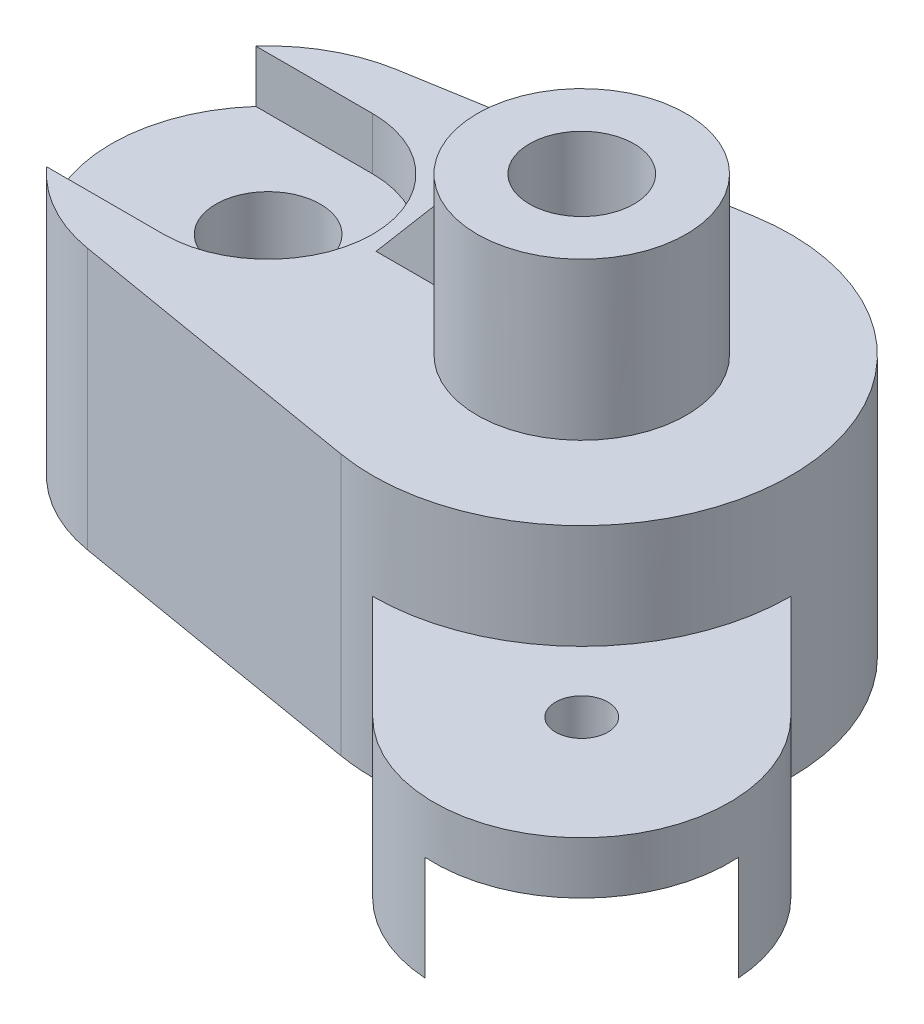
from build123d import *

# Parameters (mm, degrees)
BOSS_EXTRUDE1_DEPTH        = 50
SKETCH2_R                  = 30
CUT_EXTRUDE1_DEPTH         = 30
SKETCH3_R                  = 20
BOSS_EXTRUDE2_DEPTH        = 30
F_20_0MM_DOWEL_HOLE1_D     = 20
F_20_0MM_DOWEL_HOLE1_DEPTH = 30
F_20_0MM_DOWEL_HOLE1_TIP   = 6.00860619
SKETCH6_R                  = 10
CUT_EXTRUDE2_DEPTH         = 109
SKETCH7_R                  = 10
CUT_EXTRUDE3_DEPTH         = 10
BOSS_EXTRUDE3_DEPTH        = 30
SKETCH11_R                 = 5
CUT_EXTRUDE4_DEPTH         = 30
SKETCH13_R                 = 5
CUT_EXTRUDE5_DEPTH         = 20
SKETCH14_W                 = 17
SKETCH14_H                 = 5
BOSS_EXTRUDE4_DEPTH        = 20
SKETCH15_W                 = 91.222515674
SKETCH15_H                 = 40
CUT_EXTRUDE6_DEPTH         = 20
CUT_EXTRUDE7_DEPTH         = 20


with BuildPart() as part:
    # Sketch1 → Boss-Extrude1 (new body)
    with BuildSketch(Plane(origin=(0, 0, 0), x_dir=(1, 0, 0), z_dir=(0, 1, 0))):
        with BuildLine():
            Line((-6.666666667, 39.440531887), (-65, 29.580398915))
            ThreePointArc((-65, 29.580398915), (-74.494747679, 26.265991124), (-82.360679775, 20))
            ThreePointArc((-82.360679775, 20), (-90, 0), (-82.360679775, -20))
            ThreePointArc((-82.360679775, -20), (-74.494747679, -26.265991124), (-65, -29.580398915))
            Line((-65, -29.580398915), (-6.666666667, -39.440531887))
            ThreePointArc((-6.666666667, -39.440531887), (-3.345050411, -39.859887578), (0, -40))
            ThreePointArc((0, -40), (40, 0), (0, 40))
            ThreePointArc((0, 40), (-3.345050411, 39.859887578), (-6.666666667, 39.440531887))
        make_face()
    extrude(amount=BOSS_EXTRUDE1_DEPTH)

    # Sketch2 → Cut-Extrude1 (cut)
    with BuildSketch(Plane.XZ):
        Circle(SKETCH2_R)
    extrude(amount=-CUT_EXTRUDE1_DEPTH, mode=Mode.SUBTRACT)

    # Sketch3 → Boss-Extrude2 (add)
    with BuildSketch(Plane(origin=(0, 50, 0), x_dir=(1, 0, 0), z_dir=(0, 1, 0))):
        Circle(SKETCH3_R)
    extrude(amount=BOSS_EXTRUDE2_DEPTH)

    # Ø20.0mm Dowel Hole1
    with Locations(Plane.ZX.offset(80)):
        with Locations((0, 0)):
            Hole(F_20_0MM_DOWEL_HOLE1_D / 2, depth=F_20_0MM_DOWEL_HOLE1_DEPTH)
            with Locations((0, 0, -(F_20_0MM_DOWEL_HOLE1_DEPTH + F_20_0MM_DOWEL_HOLE1_TIP / 2))):  # 118° drill point
                Cone(0, F_20_0MM_DOWEL_HOLE1_D / 2, F_20_0MM_DOWEL_HOLE1_TIP, mode=Mode.SUBTRACT)

    # Sketch6 → Cut-Extrude2 (cut)
    with BuildSketch(Plane(origin=(0, 50, 0), x_dir=(1, 0, 0), z_dir=(0, 1, 0))):
        with Locations((-60, 0)):
            Circle(SKETCH6_R)
    extrude(amount=-CUT_EXTRUDE2_DEPTH, mode=Mode.SUBTRACT)

    # Sketch7 → Cut-Extrude3 (cut)
    with BuildSketch(Plane(origin=(0, 50, 0), x_dir=(1, 0, 0), z_dir=(0, 1, 0))):
        with BuildLine():
            ThreePointArc((-60, -20), (-40, 0), (-60, 20))
            Line((-60, 20), (-82.360679775, 20))
            ThreePointArc((-82.360679775, 20), (-90, 0), (-82.360679775, -20))
            Line((-82.360679775, -20), (-60, -20))
        make_face()
        with Locations((-60, 0)):
            Circle(SKETCH7_R, mode=Mode.SUBTRACT)
    extrude(amount=-CUT_EXTRUDE3_DEPTH, mode=Mode.SUBTRACT)

    # Sketch10 → Boss-Extrude3 (add)
    with BuildSketch(Plane.XZ):
        with BuildLine():
            Line((20, 60), (0, 40))
            ThreePointArc((0, 40), (28.284271247, 28.284271247), (40, 0))
            Line((40, 0), (60, 20))
            ThreePointArc((60, 20), (60, 60), (20, 60))
        make_face()
    extrude(amount=-BOSS_EXTRUDE3_DEPTH)

    # Sketch11 → Cut-Extrude4 (cut)
    with BuildSketch(Plane(origin=(0, 0, 0), x_dir=(-1, 0, 0), z_dir=(0, -1, 0))):
        with Locations((-40, -40)):
            Circle(SKETCH11_R)
    extrude(amount=-CUT_EXTRUDE4_DEPTH, mode=Mode.SUBTRACT)

    # Sketch13 → Cut-Extrude5 (cut)
    with BuildSketch(Plane(origin=(0, 0, 0), x_dir=(-1, 0, 0), z_dir=(0, -1, 0))):
        with BuildLine():
            ThreePointArc((-68.228756555, -38.228756555), (-60, -60), (-38.228756555, -68.228756555))
            Line((-38.228756555, -68.228756555), (0, -30))
            ThreePointArc((0, -30), (-21.213203436, -21.213203436), (-30, 0))
            Line((-30, 0), (-68.228756555, -38.228756555))
        make_face()
        with Locations((-40, -40)):
            Circle(SKETCH13_R, mode=Mode.SUBTRACT)
    extrude(amount=-CUT_EXTRUDE5_DEPTH, mode=Mode.SUBTRACT)

    # Sketch14 → Boss-Extrude4 (add)
    with BuildSketch(Plane(origin=(0, 50, 0), x_dir=(1, 0, 0), z_dir=(0, 1, 0))):
        with Locations((-28.343134833, 0)):
            Rectangle(SKETCH14_W, SKETCH14_H)
    extrude(amount=BOSS_EXTRUDE4_DEPTH)

    # Sketch15 → Cut-Extrude6 (cut)
    with BuildSketch(Plane.XZ):
        with Locations((-60, 0)):
            Rectangle(SKETCH15_W, SKETCH15_H)
    extrude(amount=-CUT_EXTRUDE6_DEPTH, mode=Mode.SUBTRACT)

    # Sketch16 → Cut-Extrude7 (cut)
    with BuildSketch(Plane.XY.offset(2.5)):
        Polygon((-19.843134833, 70), (-36.843134833, 50), (-36.843134833, 70), align=None)
    extrude(amount=-CUT_EXTRUDE7_DEPTH, mode=Mode.SUBTRACT)


solid = part.part
